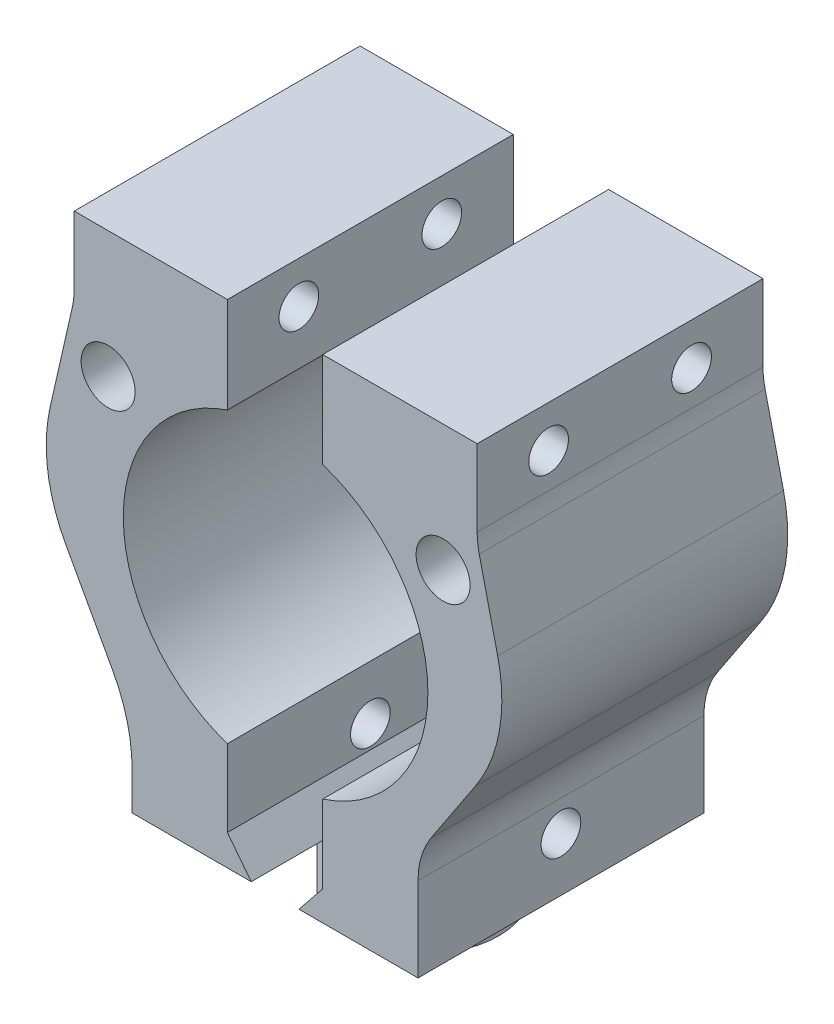
from build123d import *

# Parameters (mm, degrees)
SKETCH2_W                 = 12
SKETCH2_H                 = 18
EXTRUDE1_DEPTH            = 31.75
EXTRUDE1_2_DEPTH          = 31.75
EXTRUDE2_DEPTH            = 4.5
SKETCH4_R                 = 9.5885
MAGNET_CAVITY_DEPTH       = 19
M3X0_5_TAPPED_HOLE1_D     = 2.5
M2X0_4_TAPPED_HOLE2_D     = 1.6
M2X0_4_TAPPED_HOLE2_DEPTH = 6
M2X0_4_TAPPED_HOLE2_TIP   = 0.480688495
M3_CLEARANCE_HOLE1_D      = 3.4
M3_CLEARANCE_HOLE1_DEPTH  = 18
M3_CLEARANCE_HOLE1_TIP    = 1.021463052
EXTRUDE3_DEPTH            = 19
EXTRUDE4_DEPTH            = 18
EXTRUDE5_DEPTH            = 19
EXTRUDE6_DEPTH            = 18


with BuildPart() as part:
    # Sketch2 → Extrude1 (new body)
    with BuildSketch(Plane(origin=(0, 4.5, 0), x_dir=(-1, 0, 0), z_dir=(0, 1, 0))):
        with Locations((9, 0.343878918)):
            Rectangle(SKETCH2_W, SKETCH2_H)
    extrude(amount=EXTRUDE1_DEPTH)



with BuildPart() as body_2:
    # Sketch2 → Extrude1 2 (new body)
    with BuildSketch(Plane(origin=(0, 4.5, 0), x_dir=(-1, 0, 0), z_dir=(0, 1, 0))):
        with Locations((-9, 0.343878918)):
            Rectangle(SKETCH2_W, SKETCH2_H)
    extrude(amount=EXTRUDE1_2_DEPTH)


with BuildPart() as part_1:
    add(part.part)

    add(body_2.part)  # Extrude2 merges body 2
    # Sketch1 → Extrude2 (add)
    with BuildSketch(Plane(origin=(0, 0, 0), x_dir=(1, 0, 0), z_dir=(0, 1, 0))):
        with BuildLine():
            ThreePointArc((4.75, 0), (3.852758752, 2.778263846), (1.5, 4.506939094))
            Line((1.5, 4.506939094), (1.5, -4.506939094))
            ThreePointArc((1.5, -4.506939094), (3.852758752, -2.778263846), (4.75, 0))
        make_face()
        with BuildLine():
            Line((-1.5, -4.506939094), (-1.5, 4.506939094))
            ThreePointArc((-1.5, 4.506939094), (-4.75, 0), (-1.5, -4.506939094))
        make_face()
    extrude(amount=EXTRUDE2_DEPTH)

    # Sketch4 → Magnet Cavity (cut, through all)
    with BuildSketch(Plane.XY.offset(9.343878918)):
        with Locations((0.033766691, 20.375)):
            Circle(SKETCH4_R)
    extrude(amount=-MAGNET_CAVITY_DEPTH, mode=Mode.SUBTRACT)

    # M3x0.5 Tapped Hole1 (through all)
    with Locations(Plane(origin=(15, 32.871578641, 4.843878918), x_dir=(0, 0, 1), z_dir=(1, 0, 0))):
        with Locations((0, 0), (-9, 0), (-4.5, 24.993157282)):
            Hole(M3X0_5_TAPPED_HOLE1_D / 2)

    # M2x0.4 Tapped Hole2
    with Locations(Plane(origin=(-6.495190528, 4.5, 3.75), x_dir=(0, 0, -1), z_dir=(0, -1, 0))):
        with Locations((0, 0), (0, 12.990381056)):
            Hole(M2X0_4_TAPPED_HOLE2_D / 2, depth=M2X0_4_TAPPED_HOLE2_DEPTH)
            with Locations((0, 0, -(M2X0_4_TAPPED_HOLE2_DEPTH + M2X0_4_TAPPED_HOLE2_TIP / 2))):  # 118° drill point
                Cone(0, M2X0_4_TAPPED_HOLE2_D / 2, M2X0_4_TAPPED_HOLE2_TIP, mode=Mode.SUBTRACT)

    # M3 Clearance Hole1
    with Locations(Plane(origin=(-10.511737105, 27.54122981, 9.343878918), x_dir=(1, 0, 0), z_dir=(0, 0, 1))):
        with Locations((0, 0), (21.091007592, 0)):
            Hole(M3_CLEARANCE_HOLE1_D / 2, depth=M3_CLEARANCE_HOLE1_DEPTH)
            with Locations((0, 0, -(M3_CLEARANCE_HOLE1_DEPTH + M3_CLEARANCE_HOLE1_TIP / 2))):  # 118° drill point
                Cone(0, M3_CLEARANCE_HOLE1_D / 2, M3_CLEARANCE_HOLE1_TIP, mode=Mode.SUBTRACT)

    # Trim Sketch → Extrude3 (cut, through all)
    with BuildSketch(Plane.XY.offset(9.343878918)):
        with BuildLine():
            Line((9, 9.805409948), (9, 4.5))
            Line((9, 4.5), (15, 4.5))
            Line((15, 4.5), (15, 36.25))
            Line((15, 36.25), (3, 36.25))
            Line((3, 36.25), (3, 35.497310661))
            Line((3, 35.497310661), (12.724200068, 35.497310661))
            Line((12.724200068, 35.497310661), (12.724200068, 30.679595884))
            ThreePointArc((12.724200068, 30.679595884), (12.757175017, 30.10630526), (12.855664924, 29.540576328))
            Line((12.855664924, 29.540576328), (14.017302884, 24.575362865))
            ThreePointArc((14.017302884, 24.575362865), (14.123221889, 20.532228354), (12.6190094, 16.777830894))
            Line((12.6190094, 16.777830894), (9.830611598, 12.565156378))
            ThreePointArc((9.830611598, 12.565156378), (9.212153824, 11.246426602), (9, 9.805409948))
        make_face()
    extrude(amount=-EXTRUDE3_DEPTH, mode=Mode.SUBTRACT)

    # Sketch26 → Extrude4 (add)
    with BuildSketch(Plane.XY.offset(9.343878918)):
        Polygon((1.5, 4.5), (3, 6.359966873), (3, 4.5), align=None)
    extrude(amount=-EXTRUDE4_DEPTH)

    # Sketch27 → Extrude5 (cut, through all)
    with BuildSketch(Plane.XY.offset(9.343878918)):
        with BuildLine():
            ThreePointArc((-13.174851017, 17.046466622), (-14.310417023, 20.471304097), (-14.156594035, 24.076211914))
            Line((-14.156594035, 24.076211914), (-12.770998882, 30.156772756))
            ThreePointArc((-12.770998882, 30.156772756), (-12.677370472, 30.708713017), (-12.646030039, 31.267660339))
            Line((-12.646030039, 31.267660339), (-12.646030039, 35.497506653))
            Line((-12.646030039, 35.497506653), (-3, 35.497506653))
            Line((-3, 35.497506653), (-3, 36.25))
            Line((-3, 36.25), (-15, 36.25))
            Line((-15, 36.25), (-15, 4.5))
            Line((-15, 4.5), (-9, 4.5))
            Line((-9, 4.5), (-9, 6.871021997))
            ThreePointArc((-9, 6.871021997), (-9.312812767, 9.352635085), (-10.231680704, 11.678992122))
            Line((-10.231680704, 11.678992122), (-13.174851017, 17.046466622))
        make_face()
    extrude(amount=-EXTRUDE5_DEPTH, mode=Mode.SUBTRACT)

    # Sketch28 → Extrude6 (add)
    with BuildSketch(Plane.XY.offset(9.343878918)):
        Polygon((-1.5, 4.5), (-3, 6.43381033), (-3, 4.5), align=None)
    extrude(amount=-EXTRUDE6_DEPTH)


solid = part_1.part
